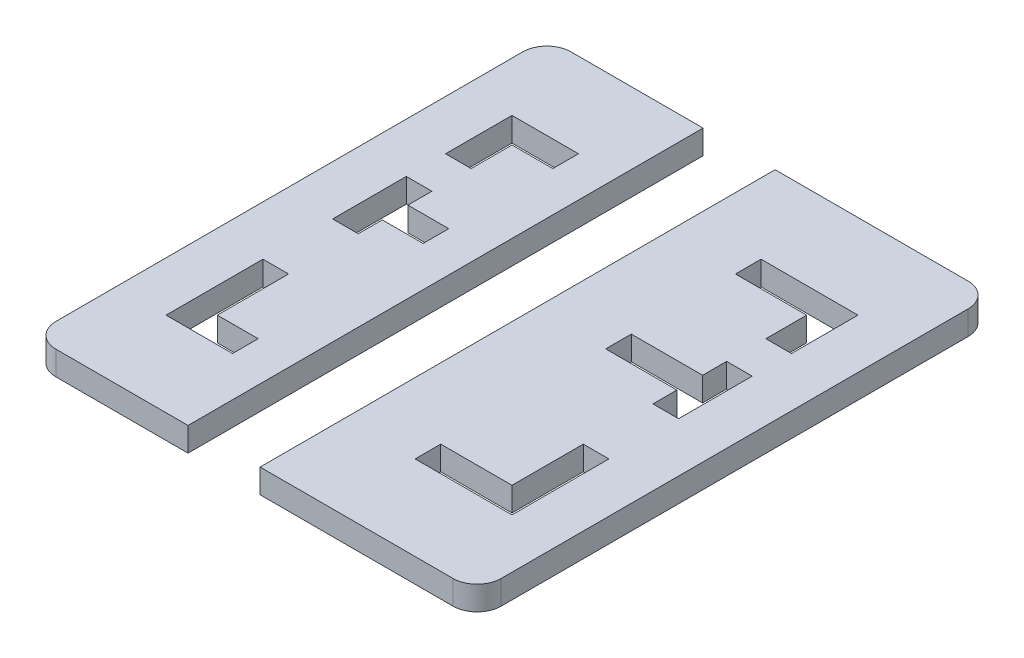
from build123d import *

# Parameters (mm, degrees)
SKETCH1_W             = 27.1
SKETCH1_H             = 64.314018284
BOSS_EXTRUDE1_DEPTH   = 3
SKETCH1_W_2           = 19.5
BOSS_EXTRUDE1_2_DEPTH = 3
CUT_EXTRUDE1_DEPTH    = 4
FILLET1_R             = 3
FILLET2_R             = 3


with BuildPart() as part:
    # Sketch1 → Boss-Extrude1 (new body)
    with BuildSketch(Plane(origin=(0, 0, 0), x_dir=(1, 0, 0), z_dir=(0, 1, 0))):
        with Locations((14.25, 0)):
            Rectangle(SKETCH1_W, SKETCH1_H)
    extrude(amount=BOSS_EXTRUDE1_DEPTH)


with BuildPart() as body_2:
    # Sketch1 → Boss-Extrude1 2 (new body)
    with BuildSketch(Plane(origin=(0, 0, 0), x_dir=(1, 0, 0), z_dir=(0, 1, 0))):
        with Locations((-18.05, 0)):
            Rectangle(SKETCH1_W_2, SKETCH1_H)
    extrude(amount=BOSS_EXTRUDE1_2_DEPTH)


with BuildPart() as cut_extrude1_tool:
    # Sketch4 → Cut-Extrude1 (new body, through all)
    with BuildSketch(Plane(origin=(0, 0, 0), x_dir=(1, 0, 0), z_dir=(0, 1, 0))):
        Polygon((18.4, 2.2), (18.4, -0.8), (21.6, -0.8), (21.6, 8.4), (18.4, 8.4), (18.4, 5.4), (9.5, 5.4), (9.5, 2.2), align=None)
        Polygon((9.5, -18.4), (9.5, -21.6), (21.6, -21.6), (21.6, -9.5), (18.4, -9.5), (18.4, -18.4), align=None)
        Polygon((-13.3, -18.4), (-18.4, -18.4), (-18.4, -9.5), (-21.6, -9.5), (-21.6, -21.6), (-13.3, -21.6), align=None)
        Polygon((-18.4, 5.4), (-18.4, 8.4), (-21.6, 8.4), (-21.6, -0.8), (-18.4, -0.8), (-18.4, 2.2), (-13.3, 2.2), (-13.3, 5.4), align=None)
        Polygon((-18.4, 18.4), (-13.3, 18.4), (-13.3, 21.6), (-21.6, 21.6), (-21.6, 13.3), (-18.4, 13.3), align=None)
        Polygon((18.4, 18.4), (18.4, 13.3), (21.6, 13.3), (21.6, 21.6), (9.5, 21.6), (9.5, 18.4), align=None)
    extrude(amount=CUT_EXTRUDE1_DEPTH)


with BuildPart() as part_1:
    add(part.part)

    # Cut-Extrude1: cut by cut_extrude1_tool
    add(cut_extrude1_tool.part, mode=Mode.SUBTRACT)

    # Fillet1
    fillet1_edges = [part_1.edges().sort_by_distance(p)[0] for p in [
        (27.8, 1.5, -32.157009142),
        (27.8, 1.5, 32.157009142),
    ]]
    fillet(fillet1_edges, radius=FILLET1_R)


with BuildPart() as body_2_1:
    add(body_2.part)

    # Cut-Extrude1: cut by cut_extrude1_tool
    add(cut_extrude1_tool.part, mode=Mode.SUBTRACT)

    # Fillet2
    fillet2_edges = [body_2_1.edges().sort_by_distance(p)[0] for p in [
        (-27.8, 1.5, 32.157009142),
        (-27.8, 1.5, -32.157009142),
    ]]
    fillet(fillet2_edges, radius=FILLET2_R)


solid = Compound([part_1.part, body_2_1.part])
